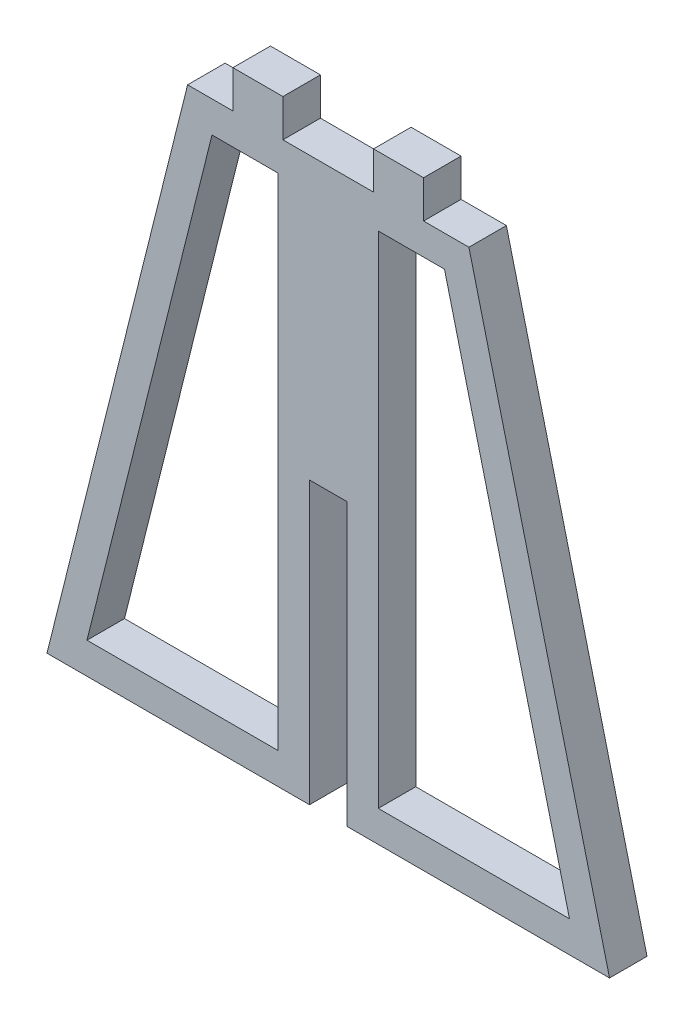
from build123d import *

# Parameters (mm, degrees)
BOSS_EXTRUDE4_DEPTH = 6


with BuildPart() as part:
    # Sketch2 → Boss-Extrude4 (new body)
    with BuildSketch(Plane.XY):
        Polygon((45, 9.865384615), (3, 9.865384615), (3, 54.865384615), (-3, 54.865384615), (-3, 9.865384615), (-45, 9.865384615), (-22.5, 99.865384615), (-15.25, 99.865384615), (-15.25, 105.865384615), (-7.25, 105.865384615), (-7.25, 99.865384615), (7.25, 99.865384615), (7.25, 105.865384615), (15.25, 105.865384615), (15.25, 99.865384615), (22.5, 99.865384615), align=None)
        Polygon((-8, 94.865384615), (-18.596117968, 94.865384615), (-38.596117968, 14.865384615), (-8, 14.865384615), align=None, mode=Mode.SUBTRACT)
        Polygon((38.596117968, 14.865384615), (8, 14.865384615), (8, 94.865384615), (18.596117968, 94.865384615), align=None, mode=Mode.SUBTRACT)
    extrude(amount=BOSS_EXTRUDE4_DEPTH)


solid = part.part
